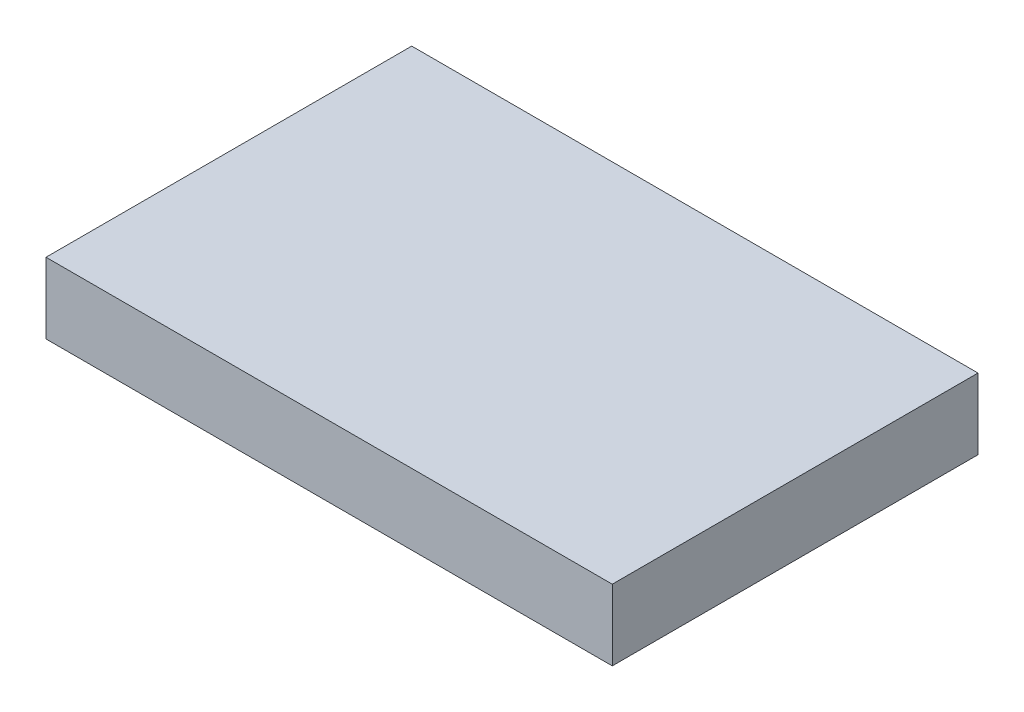
from build123d import *

# Parameters (mm, degrees)
SKETCH1_W           = 60.96
SKETCH1_H           = 39.37
BOSS_EXTRUDE1_DEPTH = 7.62


with BuildPart() as part:
    # Sketch1 → Boss-Extrude1 (new body)
    with BuildSketch(Plane(origin=(0, 0, 0), x_dir=(1, 0, 0), z_dir=(0, 1, 0))):
        Rectangle(SKETCH1_W, SKETCH1_H)
    extrude(amount=BOSS_EXTRUDE1_DEPTH)


solid = part.part
